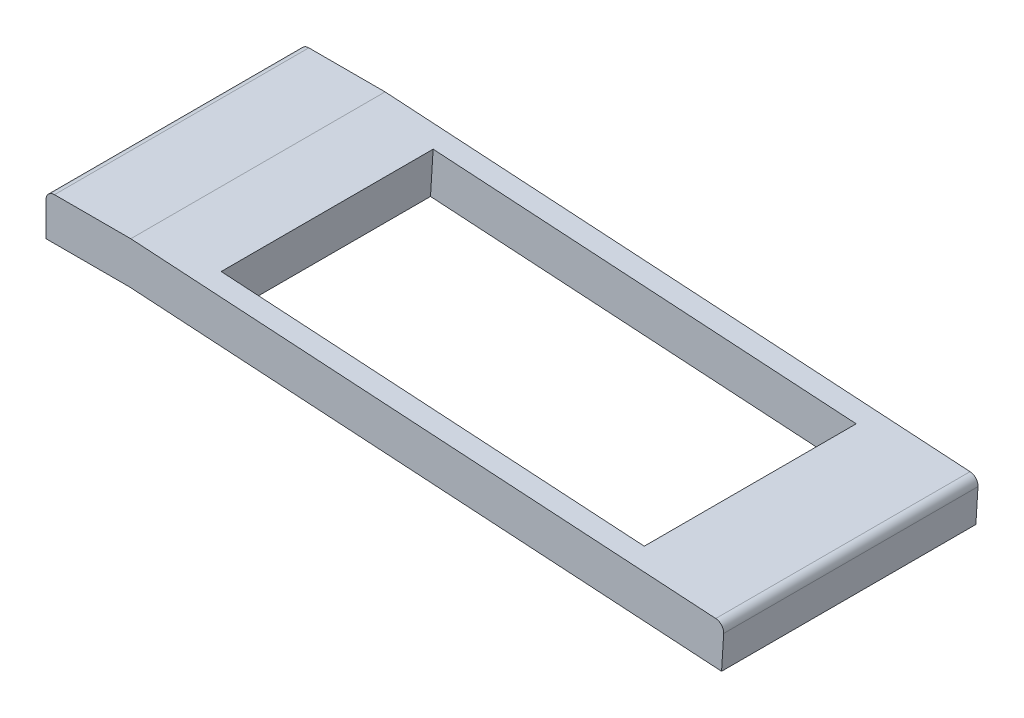
from build123d import *

# Parameters (mm, degrees)
BOSS_EXTRUDE3_DEPTH = 3
SKETCH3_W           = 5
SKETCH3_H           = 2.5
CUT_EXTRUDE1_DEPTH  = 3


with BuildPart() as part:
    # Sketch2 → Boss-Extrude3 (new body)
    with BuildSketch(Plane.XY):
        with BuildLine():
            Line((0.1, 0), (1, 0))
            Line((1, 0), (7.900193166, -0.429508089))
            ThreePointArc((7.900193166, -0.429508089), (7.968947639, -0.463133775), (7.993787443, -0.53552748))
            Line((7.993787443, -0.53552748), (7.968937216, -0.934754817))
            Line((7.968937216, -0.934754817), (0.984453593, -0.5))
            Line((0.984453593, -0.5), (0, -0.5))
            Line((0, -0.5), (0, -0.1))
            ThreePointArc((0, -0.1), (0.029289322, -0.029289322), (0.1, 0))
        make_face()
    extrude(amount=BOSS_EXTRUDE3_DEPTH)

    # Sketch3 → Cut-Extrude1 (cut)
    with BuildSketch(Plane(origin=(0.003859586, 0.062005564, 0), x_dir=(0.998068341, -0.062125569, 0), z_dir=(0.062125569, 0.998068341, 0))):
        with Locations((4.317122221, -1.500788282)):
            Rectangle(SKETCH3_W, SKETCH3_H)
    extrude(amount=-CUT_EXTRUDE1_DEPTH, mode=Mode.SUBTRACT)


solid = part.part
